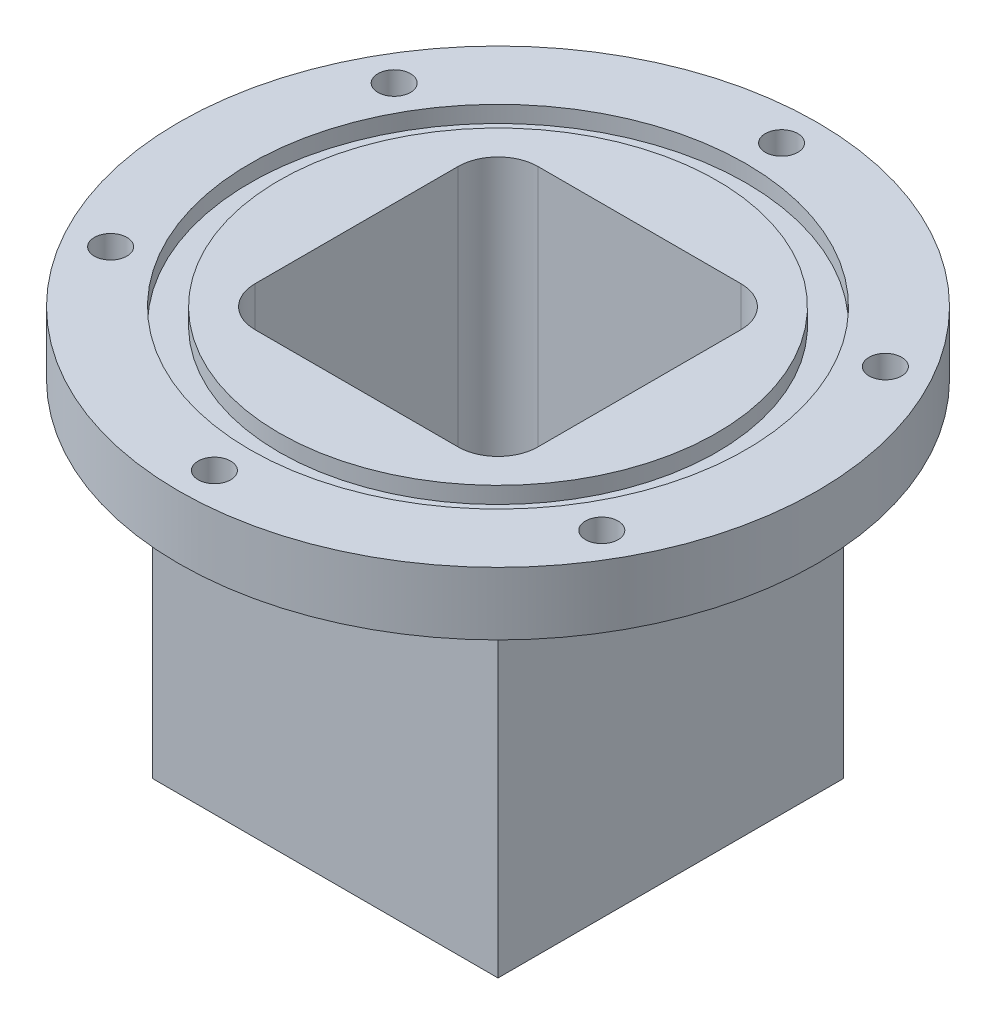
from build123d import *

# Parameters (mm, degrees)
SKETCH1_W                  = 55
SKETCH1_H                  = 55
SKETCH1_W_2                = 45
SKETCH1_H_2                = 45
BOSS_EXTRUDE1_DEPTH        = 5
SKETCH1_3_W                = 55
SKETCH1_3_H                = 55
SKETCH1_3_W_2              = 45
SKETCH1_3_H_2              = 45
BOSS_EXTRUDE2_DEPTH        = 60
SKETCH6_R                  = 50.8
SKETCH6_W                  = 55
SKETCH6_H                  = 55
BOSS_EXTRUDE4_DEPTH        = 10
SKETCH7_R                  = 12
BOSS_EXTRUDE5_DEPTH        = 10
F_6_0_204_DIAMETER_HOLE2_D = 5.1816
SKETCH11_R                 = 7
CUT_EXTRUDE1_DEPTH         = 10
SKETCH13_R                 = 39.439805153
SKETCH13_R_2               = 34.819805153
CUT_EXTRUDE3_DEPTH         = 2.64
FILLET2_R                  = 6.35
F_6_0_204_DIAMETER_HOLE1_D = 5.1816
CIRPATTERN2_COUNT          = 6


with BuildPart() as part:
    # Sketch1 → Boss-Extrude1 (new body)
    with BuildSketch(Plane(origin=(0, 0, 0), x_dir=(1, 0, 0), z_dir=(0, 1, 0))):
        Rectangle(SKETCH1_W, SKETCH1_H)
        Rectangle(SKETCH1_W_2, SKETCH1_H_2, mode=Mode.SUBTRACT)
        Rectangle(SKETCH1_W_2, SKETCH1_H_2)
    extrude(amount=-BOSS_EXTRUDE1_DEPTH)

    # Sketch1_3 → Boss-Extrude2 (add)
    with BuildSketch(Plane(origin=(0, 0, 0), x_dir=(1, 0, 0), z_dir=(0, 1, 0))):
        Rectangle(SKETCH1_3_W, SKETCH1_3_H)
        Rectangle(SKETCH1_3_W_2, SKETCH1_3_H_2, mode=Mode.SUBTRACT)
    extrude(amount=BOSS_EXTRUDE2_DEPTH)

    # Sketch6 → Boss-Extrude4 (add)
    with BuildSketch(Plane(origin=(0, 60, 0), x_dir=(1, 0, 0), z_dir=(0, 1, 0))):
        with Locations(Location((0, 0, 0), (0, 0, 270))):
            Circle(SKETCH6_R)
        Rectangle(SKETCH6_W, SKETCH6_H, mode=Mode.SUBTRACT)
    extrude(amount=-BOSS_EXTRUDE4_DEPTH)

    # Sketch7 → Boss-Extrude5 (add)
    with BuildSketch(Plane.XZ.offset(5)):
        with Locations(Location((0, 0, 0), (0, 0, 90))):
            Circle(SKETCH7_R)
    extrude(amount=BOSS_EXTRUDE5_DEPTH)

    # 6 _0.204_ Diameter Hole2 (through all)
    with Locations(Plane(origin=(0, -15, 0), x_dir=(-1, 0, 0), z_dir=(0, -1, 0))):
        with Locations((0, 0)):
            Hole(F_6_0_204_DIAMETER_HOLE2_D / 2)

    # Sketch11 → Cut-Extrude1 (cut)
    with BuildSketch(Plane.XZ.offset(15)):
        with Locations(Location((0, 0, 0), (0, 0, 270))):
            Circle(SKETCH11_R)
    extrude(amount=-CUT_EXTRUDE1_DEPTH, mode=Mode.SUBTRACT)

    # Sketch13 → Cut-Extrude3 (cut)
    with BuildSketch(Plane(origin=(0, 60, 0), x_dir=(1, 0, 0), z_dir=(0, 1, 0))):
        with Locations(Location((0, 0, 0), (0, 0, 270))):
            Circle(SKETCH13_R)
        with Locations(Location((0, 0, 0), (0, 0, 270))):
            Circle(SKETCH13_R_2, mode=Mode.SUBTRACT)
    extrude(amount=-CUT_EXTRUDE3_DEPTH, mode=Mode.SUBTRACT)

    # Fillet2
    fillet2_edges = [part.edges().sort_by_distance(p)[0] for p in [
        (22.5, 30, 22.5),
        (-22.5, 30, 22.5),
        (-22.5, 30, -22.5),
        (22.5, 30, -22.5),
    ]]
    fillet(fillet2_edges, radius=FILLET2_R)

    # 6 _0.204_ Diameter Hole1 (through all)
    with Locations(Plane(origin=(0, 60, 0), x_dir=(1, 0, 0), z_dir=(0, 1, 0))):
        with Locations((-39.074981848, -22.559951288)):
            f_6_0_204_diameter_hole1 = Hole(F_6_0_204_DIAMETER_HOLE1_D / 2)

    # CirPattern2: 6 _0.204_ Diameter Hole1 ×6 about axis
    cirpattern2_axis = Axis((0, 0, 0), (0, 1, 0))
    for i in range(1, CIRPATTERN2_COUNT):
        add(f_6_0_204_diameter_hole1.rotate(cirpattern2_axis, i * 360 / CIRPATTERN2_COUNT), mode=Mode.SUBTRACT)


solid = part.part
